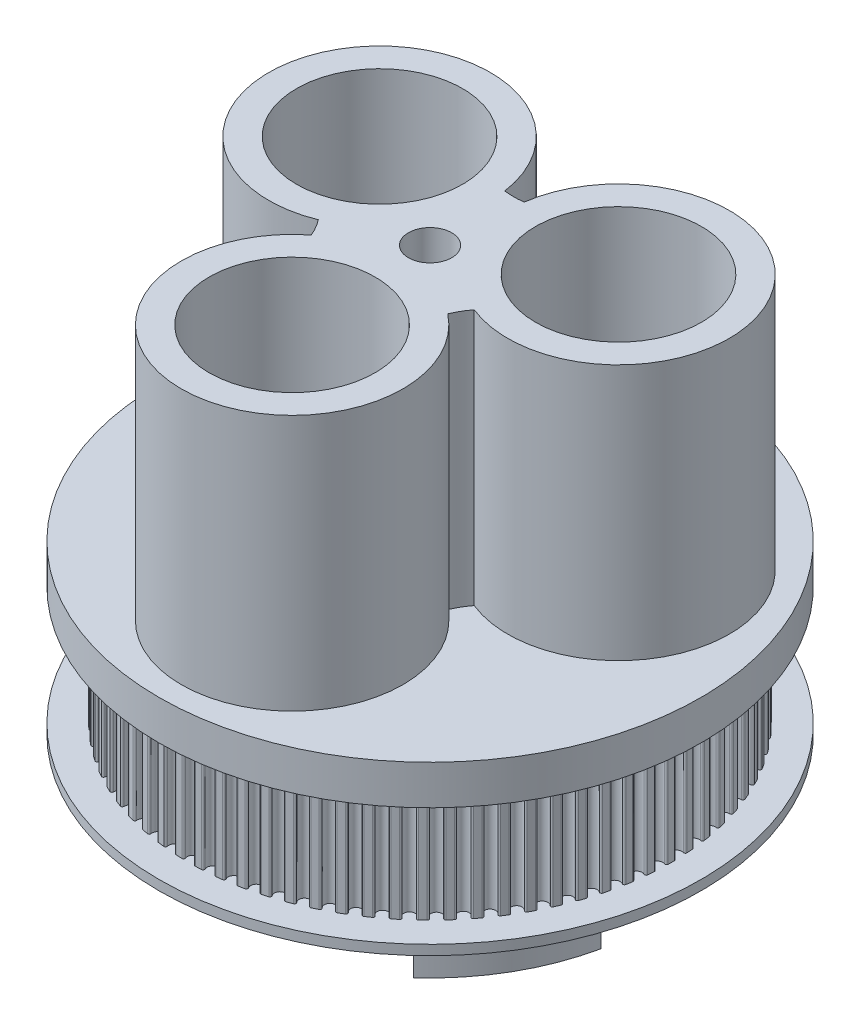
from build123d import *

# Parameters (mm, degrees)
SKETCH1_R                = 27.5
SKETCH1_R_2              = 2.2
SKETCH1_R_3              = 8.425
BOSS_EXTRUDE1_DEPTH      = 43
SKETCH4_W                = 3
SKETCH4_H                = 12
SKETCH5_R                = 27.5
CUT_EXTRUDE3_DEPTH       = 26
BOSS_EXTRUDE2_DEPTH      = 5.5
SKETCH9_R                = 0.56
CUT_EXTRUDE11_DEPTH      = 12
FILLET1_R                = 0.16
CIRPATTERN1_COUNT        = 78
FILLET1_OF_CIRPATTERN1_R = 0.16


with BuildPart() as part:
    # Sketch1 → Boss-Extrude1 (new body)
    with BuildSketch(Plane(origin=(0, 0, 0), x_dir=(1, 0, 0), z_dir=(0, 1, 0))):
        with Locations(Location((0, 0, 0), (0, 0, 270))):
            Circle(SKETCH1_R)
        with Locations(Location((0, 0, 0), (0, 0, 270))):
            Circle(SKETCH1_R_2, mode=Mode.SUBTRACT)
        with Locations(Location((0, -14, 0), (0, 0, 270))):
            Circle(SKETCH1_R_3, mode=Mode.SUBTRACT)
        with Locations(Location((-12.124355653, 7, 0), (0, 0, 270))):
            Circle(SKETCH1_R_3, mode=Mode.SUBTRACT)
        with Locations(Location((12.124355653, 7, 0), (0, 0, 270))):
            Circle(SKETCH1_R_3, mode=Mode.SUBTRACT)
    extrude(amount=BOSS_EXTRUDE1_DEPTH)

    # Sketch4 → Cut-Revolve1 (revolve, cut)
    with BuildSketch(Plane(origin=(0, 0, 0), x_dir=(0, 0, -1), z_dir=(1, 0, 0)), mode=Mode.PRIVATE) as cut_revolve1_sk:
        with Locations((26, 7)):
            Rectangle(SKETCH4_W, SKETCH4_H)
    revolve(cut_revolve1_sk.sketch.rotate(Axis((0, 27.01947496, 0), (0, -1, 0)), 180), axis=Axis((0, 27.01947496, 0), (0, -1, 0)), mode=Mode.SUBTRACT)

    # Sketch5 → Cut-Extrude3 (cut)
    with BuildSketch(Plane(origin=(0, 43, 0), x_dir=(1, 0, 0), z_dir=(0, 1, 0))):
        with Locations(Location((0, 0, 0), (0, 0, 270))):
            Circle(SKETCH5_R)
        with BuildLine():
            ThreePointArc((7.90918434, -3.430476058), (7.361215932, -4.25), (6.925471584, -5.134316533))
            ThreePointArc((6.925471584, -5.134316533), (0, -25.25), (-6.925471584, -5.134316533))
            ThreePointArc((-6.925471584, -5.134316533), (-7.361215932, -4.25), (-7.90918434, -3.430476058))
            ThreePointArc((-7.90918434, -3.430476058), (-21.867141446, 12.625), (-0.983712757, 8.564792591))
            ThreePointArc((-0.983712757, 8.564792591), (0, 8.5), (0.983712757, 8.564792591))
            ThreePointArc((0.983712757, 8.564792591), (21.867141446, 12.625), (7.90918434, -3.430476058))
        make_face(mode=Mode.SUBTRACT)
    extrude(amount=-CUT_EXTRUDE3_DEPTH, mode=Mode.SUBTRACT)

    # Sketch6 → Boss-Extrude2 (add)
    with BuildSketch(Plane.XZ):
        with BuildLine():
            Line((-11.040655005, 12.26188962), (-15.055438643, 16.720758573))
            ThreePointArc((-15.055438643, 16.720758573), (-19.485571585, 11.25), (-22.008321017, 4.678013043))
            Line((-22.008321017, 4.678013043), (-16.139435412, 3.430542898))
            ThreePointArc((-16.139435412, 3.430542898), (-14.289419162, 8.25), (-11.040655005, 12.26188962))
        make_face()
        with BuildLine():
            ThreePointArc((22.008321017, 4.678013043), (19.485571585, 11.25), (15.055438643, 16.720758573))
            Line((15.055438643, 16.720758573), (11.040655005, 12.26188962))
            ThreePointArc((11.040655005, 12.26188962), (14.289419162, 8.25), (16.139435412, 3.430542898))
            Line((16.139435412, 3.430542898), (22.008321017, 4.678013043))
        make_face()
        with BuildLine():
            Line((-5.098780407, -15.692432519), (-6.952882373, -21.398771617))
            ThreePointArc((-6.952882373, -21.398771617), (0, -22.5), (6.952882373, -21.398771617))
            Line((6.952882373, -21.398771617), (5.098780407, -15.692432519))
            ThreePointArc((5.098780407, -15.692432519), (0, -16.5), (-5.098780407, -15.692432519))
        make_face()
    extrude(amount=BOSS_EXTRUDE2_DEPTH)

    # Sketch9 → Cut-Extrude11 (cut)
    with BuildSketch(Plane(origin=(0, 13, 0), x_dir=(-1, 0, 0), z_dir=(0, -1, 0))):
        with Locations((24.051414012, -0.945718791)):
            Circle(SKETCH9_R)
    cut_extrude11 = extrude(amount=CUT_EXTRUDE11_DEPTH, mode=Mode.SUBTRACT)

    # Fillet1
    fillet1_edges = [part.edges().sort_by_distance(p)[0] for p in [
        (-24.49263088, 7, 0.60085987),
        (-24.464190307, 7, 1.324157333),
    ]]
    fillet(fillet1_edges, radius=FILLET1_R)

    # CirPattern1: Cut-Extrude11 ×78 about axis
    cirpattern1_axis = Axis((0, 0, 0), (0, 1, 0))
    for i in range(1, CIRPATTERN1_COUNT):
        add(cut_extrude11.rotate(cirpattern1_axis, i * 360 / CIRPATTERN1_COUNT), mode=Mode.SUBTRACT)

    # Fillet1 of CirPattern1
    fillet1_of_cirpattern1_edges = [part.edges().sort_by_distance(p)[0] for p in [
        (-24.364859693, 7, 2.569749432),
        (-24.278310079, 7, 3.28841295),
        (-24.079073041, 7, 4.521973183),
        (-23.934975693, 7, 5.231341946),
        (-23.637124361, 7, 6.444870203),
        (-23.436413806, 7, 7.140343682),
        (-23.041879859, 7, 8.325969767),
        (-22.785857782, 7, 9.00303755),
        (-22.297199924, 7, 10.153072221),
        (-21.987526727, 7, 10.807343264),
        (-21.407914092, 7, 11.914328107),
        (-21.046598123, 7, 12.541559211),
        (-20.379789722, 7, 13.598315002),
        (-19.969174255, 7, 14.194438333),
        (-19.219494595, 7, 15.194111607),
        (-18.762242628, 7, 15.755261075),
        (-17.93455367, 7, 16.691368567),
        (-17.433630659, 7, 17.213904904),
        (-16.533300283, 7, 18.080375597),
        (-15.991954905, 7, 18.560909954),
        (-15.0248221, 7, 19.352124454),
        (-14.446565186, 7, 19.787540381),
        (-13.418902179, 7, 20.498367357),
        (-12.807483949, 7, 20.885841015),
        (-11.725955528, 7, 21.511670482),
        (-11.085341264, 7, 21.848688955),
        (-9.956961557, 7, 22.38546217),
        (-9.291305887, 7, 22.669839764),
        (-8.123392869, 7, 23.114075545),
        (-7.437012826, 7, 23.343967962),
        (-6.23714086, 7, 23.692785271),
        (-5.534487882, 7, 23.866701571),
        (-4.3104386, 7, 24.117838192),
        (-3.596069662, 7, 24.234650461),
        (-2.355781492, 7, 24.386477678),
        (-1.634329549, 7, 24.445428344),
        (-0.385846237, 7, 24.496961499),
        (0.338009818, 7, 24.497668243),
        (1.58659138, 7, 24.448573124),
        (2.308157061, 7, 24.391031364),
        (3.548739342, 7, 24.24162637),
        (4.26333502, 7, 24.126209286),
        (5.487872368, 7, 23.877463368),
        (6.190863616, 7, 23.704919483),
        (7.391414436, 7, 23.358445852),
        (8.078242085, 7, 23.129894181),
        (9.247020344, 7, 22.687939852),
        (9.913230055, 7, 22.404862639),
        (11.042655778, 7, 21.870293856),
        (11.683926924, 7, 21.534526966),
        (12.766675351, 7, 20.910810613),
        (13.378849043, 7, 20.524531622),
        (14.407898136, 7, 19.815712738),
        (14.987004192, 7, 19.381426814),
        (15.955680173, 7, 18.592102362),
        (16.497962868, 7, 18.112626016),
        (17.399983501, 7, 17.247915067),
        (17.901925924, 7, 16.726357889),
        (18.731441259, 7, 15.791868426),
        (19.189788121, 7, 15.231612911),
        (19.941418432, 7, 14.233405457),
        (20.353197178, 7, 13.63808508),
        (21.022067855, 7, 12.582633392),
        (21.384607941, 7, 11.956109033),
        (21.966381101, 7, 10.850258122),
        (22.277331316, 7, 10.196593031),
        (22.768233937, 7, 9.047514764),
        (23.025577649, 7, 8.37094821),
        (23.422426038, 7, 7.186094801),
        (23.624494275, 7, 6.491014579),
        (23.924714719, 7, 5.278070255),
        (24.07019699, 7, 4.568984227),
        (24.271842444, 7, 3.335815399),
        (24.359795241, 7, 2.617322258),
        (24.461557957, 7, 1.371926499),
        (24.491410873, 7, 0.648685951),
        (24.49263088, 7, -0.60085987),
        (24.464190307, 7, -1.324157333),
        (24.364859693, 7, -2.569749432),
        (24.278310079, 7, -3.28841295),
        (24.079073041, 7, -4.521973183),
        (23.934975693, 7, -5.231341946),
        (23.637124361, 7, -6.444870203),
        (23.436413806, 7, -7.140343682),
        (23.041879859, 7, -8.325969767),
        (22.785857782, 7, -9.00303755),
        (22.297199924, 7, -10.153072221),
        (21.987526727, 7, -10.807343264),
        (21.407914092, 7, -11.914328107),
        (21.046598123, 7, -12.541559211),
        (20.379789722, 7, -13.598315002),
        (19.969174255, 7, -14.194438333),
        (19.219494595, 7, -15.194111607),
        (18.762242628, 7, -15.755261075),
        (17.93455367, 7, -16.691368567),
        (17.433630659, 7, -17.213904904),
        (16.533300283, 7, -18.080375597),
        (15.991954905, 7, -18.560909954),
        (15.0248221, 7, -19.352124454),
        (14.446565186, 7, -19.787540381),
        (13.418902179, 7, -20.498367357),
        (12.807483949, 7, -20.885841015),
        (11.725955528, 7, -21.511670482),
        (11.085341264, 7, -21.848688955),
        (9.956961557, 7, -22.38546217),
        (9.291305887, 7, -22.669839764),
        (8.123392869, 7, -23.114075545),
        (7.437012826, 7, -23.343967962),
        (6.23714086, 7, -23.692785271),
        (5.534487882, 7, -23.866701571),
        (4.3104386, 7, -24.117838192),
        (3.596069662, 7, -24.234650461),
        (2.355781492, 7, -24.386477678),
        (1.634329549, 7, -24.445428344),
        (0.385846237, 7, -24.496961499),
        (-0.338009818, 7, -24.497668243),
        (-1.58659138, 7, -24.448573124),
        (-2.308157061, 7, -24.391031364),
        (-3.548739342, 7, -24.24162637),
        (-4.26333502, 7, -24.126209286),
        (-5.487872368, 7, -23.877463368),
        (-6.190863616, 7, -23.704919483),
        (-7.391414436, 7, -23.358445852),
        (-8.078242085, 7, -23.129894181),
        (-9.247020344, 7, -22.687939852),
        (-9.913230055, 7, -22.404862639),
        (-11.042655778, 7, -21.870293856),
        (-11.683926924, 7, -21.534526966),
        (-12.766675351, 7, -20.910810613),
        (-13.378849043, 7, -20.524531622),
        (-14.407898136, 7, -19.815712738),
        (-14.987004192, 7, -19.381426814),
        (-15.955680173, 7, -18.592102362),
        (-16.497962868, 7, -18.112626016),
        (-17.399983501, 7, -17.247915067),
        (-17.901925924, 7, -16.726357889),
        (-18.731441259, 7, -15.791868426),
        (-19.189788121, 7, -15.231612911),
        (-19.941418432, 7, -14.233405457),
        (-20.353197178, 7, -13.63808508),
        (-21.022067855, 7, -12.582633392),
        (-21.384607941, 7, -11.956109033),
        (-21.966381101, 7, -10.850258122),
        (-22.277331316, 7, -10.196593031),
        (-22.768233937, 7, -9.047514764),
        (-23.025577649, 7, -8.37094821),
        (-23.422426038, 7, -7.186094801),
        (-23.624494275, 7, -6.491014579),
        (-23.924714719, 7, -5.278070255),
        (-24.07019699, 7, -4.568984227),
        (-24.271842444, 7, -3.335815399),
        (-24.359795241, 7, -2.617322258),
        (-24.461557957, 7, -1.371926499),
        (-24.491410873, 7, -0.648685951),
    ]]
    fillet(fillet1_of_cirpattern1_edges, radius=FILLET1_OF_CIRPATTERN1_R)


solid = part.part
